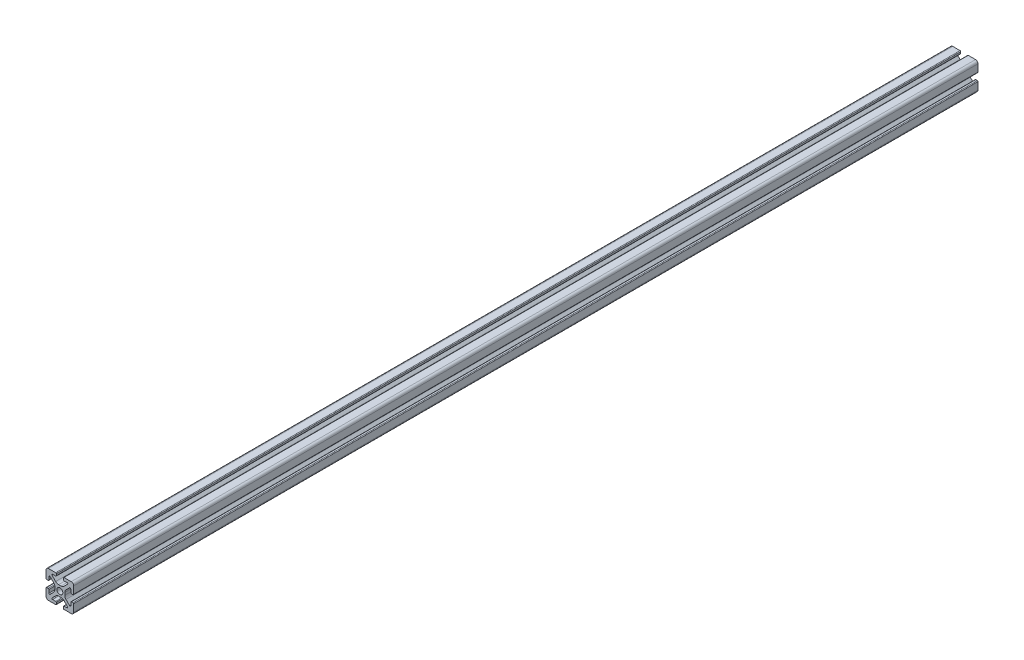
from build123d import *

# Parameters (mm, degrees)
BOSS_EXTRUDE1_DEPTH = 327.25


with BuildPart() as part:
    # Sketch4 → Boss-Extrude1 (new body, symmetric)
    with BuildSketch(Plane.XY):
        with BuildLine():
            Line((3, -10), (8.25, -10))
            ThreePointArc((8.25, -10), (9.487436867, -9.487436867), (10, -8.25))
            Line((10, -8.25), (10, -3))
            ThreePointArc((10, -3), (9.853553391, -2.646446609), (9.5, -2.5))
            Line((9.5, -2.5), (8.424621202, -2.5))
            ThreePointArc((8.424621202, -2.5), (8.071067812, -2.646446609), (7.924621202, -3))
            Line((7.924621202, -3), (7.924621202, -5.25))
            ThreePointArc((7.924621202, -5.25), (7.615962919, -5.711939766), (7.071067812, -5.603553391))
            Line((7.071067812, -5.603553391), (4.478679656, -3.011165235))
            ThreePointArc((4.478679656, -3.011165235), (3.828361402, -2.037895189), (3.6, -0.889844892))
            Line((3.6, -0.889844892), (3.6, 0))
            Line((3.6, 0), (2.15, 0))
            ThreePointArc((2.15, 0), (1.52027958, -1.52027958), (0, -2.15))
            Line((0, -2.15), (0, -3.6))
            Line((0, -3.6), (0.889844892, -3.6))
            ThreePointArc((0.889844892, -3.6), (2.037895189, -3.828361402), (3.011165235, -4.478679656))
            Line((3.011165235, -4.478679656), (5.603553391, -7.071067812))
            ThreePointArc((5.603553391, -7.071067812), (5.711939766, -7.615962919), (5.25, -7.924621202))
            Line((5.25, -7.924621202), (3, -7.924621202))
            ThreePointArc((3, -7.924621202), (2.646446609, -8.071067812), (2.5, -8.424621202))
            Line((2.5, -8.424621202), (2.5, -9.5))
            ThreePointArc((2.5, -9.5), (2.646446609, -9.853553391), (3, -10))
        make_face()
    extrude(amount=BOSS_EXTRUDE1_DEPTH, both=True)

    # Mirror1: part across plane


with BuildPart() as part_1:
    add(part.part)
    add(part.part.mirror(Plane(origin=(0, 0, 0), x_dir=(0, 0, 1), z_dir=(1, 0, 0))))

    # Mirror2: part across plane


with BuildPart() as part_2:
    add(part_1.part)
    add(part_1.part.mirror(Plane.ZX))


solid = part_2.part
